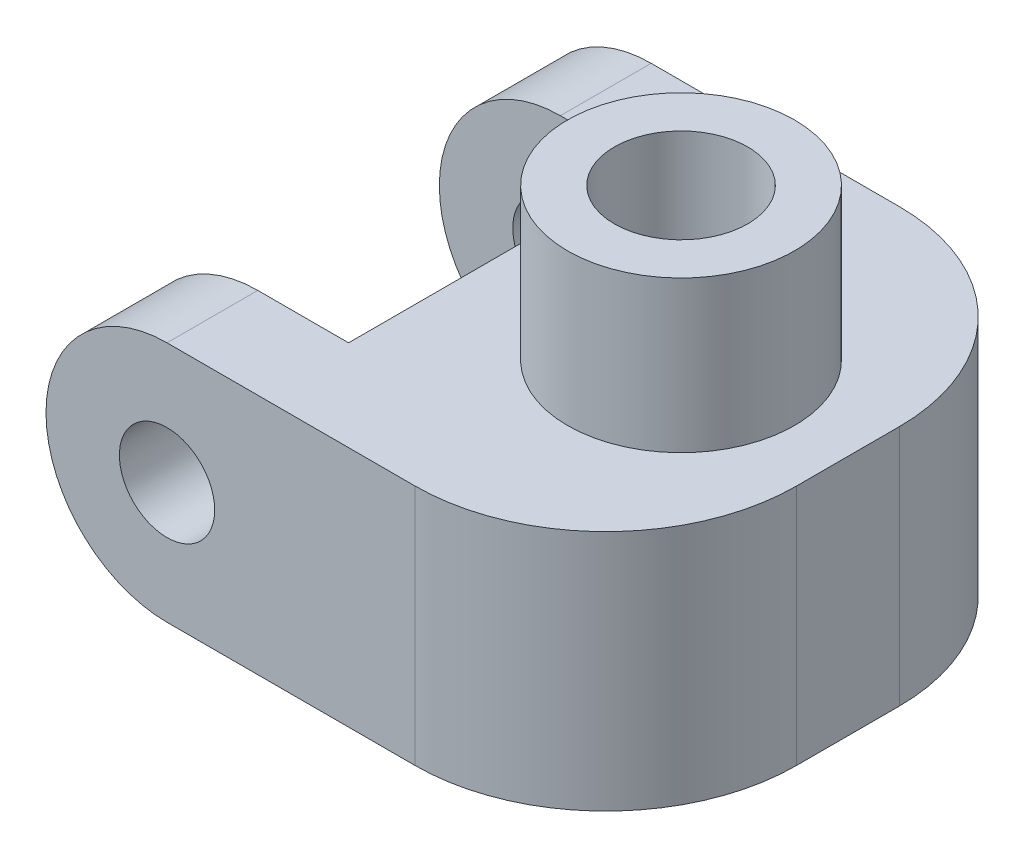
from build123d import *

# Parameters (mm, degrees)
SKETCH2_R           = 2
BOSS_EXTRUDE1_DEPTH = 20.32
SKETCH3_R           = 2
CUT_EXTRUDE1_DEPTH  = 6.35
SKETCH6_R           = 4.7625
BOSS_EXTRUDE2_DEPTH = 6.35
SKETCH7_R           = 2.8
CUT_EXTRUDE3_DEPTH  = 5
CHAMFER3_SIZE       = 7.62
CHAMFER3_SIZE2      = 4.399409051
FILLET1_R           = 8


with BuildPart() as part:
    # Sketch2 → Boss-Extrude1 (new body)
    with BuildSketch(Plane.XY):
        with BuildLine():
            ThreePointArc((0, 5.08), (-5.08, 0), (0, -5.08))
            Line((0, -5.08), (18.415, -5.08))
            Line((18.415, -5.08), (18.415, 5.08))
            Line((18.415, 5.08), (0, 5.08))
        make_face()
        Circle(SKETCH2_R, mode=Mode.SUBTRACT)
    extrude(amount=BOSS_EXTRUDE1_DEPTH)

    # Sketch3 → Cut-Extrude1 (cut, symmetric)
    with BuildSketch(Plane.XY.offset(10.16)):
        with BuildLine():
            ThreePointArc((0, 5.08), (-5.08, 0), (0, -5.08))
            ThreePointArc((0, -5.08), (2.090104165, -4.630104165), (3.81, -3.360104165))
            Line((3.81, -3.360104165), (3.81, 3.360104165))
            ThreePointArc((3.81, 3.360104165), (2.090104165, 4.630104165), (0, 5.08))
        make_face()
        Circle(SKETCH3_R, mode=Mode.SUBTRACT)
        with BuildLine():
            Line((3.81, 5.08), (0, 5.08))
            ThreePointArc((0, 5.08), (2.090104165, 4.630104165), (3.81, 3.360104165))
            Line((3.81, 3.360104165), (3.81, 5.08))
        make_face()
        with BuildLine():
            Line((0, -5.08), (3.81, -5.08))
            Line((3.81, -5.08), (3.81, -3.360104165))
            ThreePointArc((3.81, -3.360104165), (2.090104165, -4.630104165), (0, -5.08))
        make_face()
    extrude(amount=CUT_EXTRUDE1_DEPTH, both=True, mode=Mode.SUBTRACT)

    # Sketch6 → Boss-Extrude2 (add)
    with BuildSketch(Plane(origin=(0, 5.08, 0), x_dir=(1, 0, 0), z_dir=(0, 1, 0))):
        with Locations((11.415, -10.16)):
            Circle(SKETCH6_R)
    extrude(amount=BOSS_EXTRUDE2_DEPTH)

    # Sketch7 → Cut-Extrude3 (cut)
    with BuildSketch(Plane(origin=(0, 11.43, 0), x_dir=(1, 0, 0), z_dir=(0, 1, 0))):
        with Locations((11.415, -10.16)):
            Circle(SKETCH7_R)
    extrude(amount=-CUT_EXTRUDE3_DEPTH, mode=Mode.SUBTRACT)

    # Chamfer3
    chamfer3_edges = [part.edges().sort_by_distance(p)[0] for p in [
        (3.81, -5.08, 10.16),
    ]]
    chamfer3_side = [part.faces().sort_by_distance(p)[0] for p in [
        (10.292029703, -5.08, 10.16),
    ]]
    chamfer(chamfer3_edges, length=CHAMFER3_SIZE, length2=CHAMFER3_SIZE2, reference=chamfer3_side[0])

    # Fillet1
    fillet1_edges = [part.edges().sort_by_distance(p)[0] for p in [
        (18.415, 0, 20.32),
        (18.415, 0, 0),
    ]]
    fillet(fillet1_edges, radius=FILLET1_R)


solid = part.part
